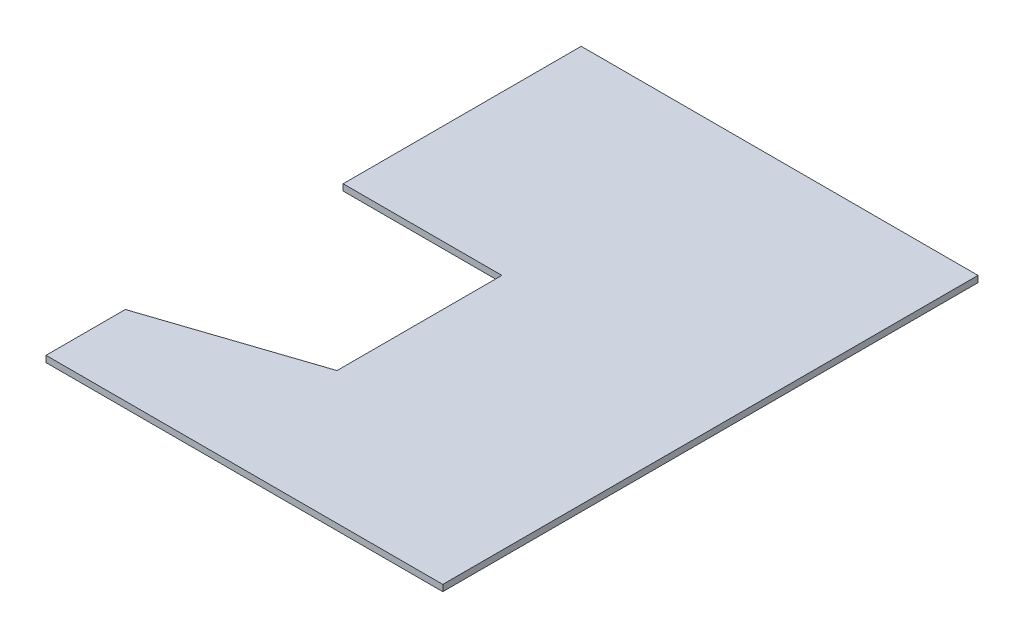
from build123d import *

# Parameters (mm, degrees)
BOSS_EXTRUDE1_DEPTH = 4


with BuildPart() as part:
    # Sketch1 → Boss-Extrude1 (new body)
    with BuildSketch(Plane(origin=(0, 0, 0), x_dir=(1, 0, 0), z_dir=(0, 1, 0))):
        Polygon((333.727349577, 132.797927461), (433.727349577, 132.797927461), (433.727349577, 28.923668594), (333.727349577, -4.409664739), (333.727349577, -54.409664739), (583.727349577, -54.409664739), (583.727349577, 282.797927461), (333.727349577, 282.797927461), align=None)
    extrude(amount=BOSS_EXTRUDE1_DEPTH)


solid = part.part
